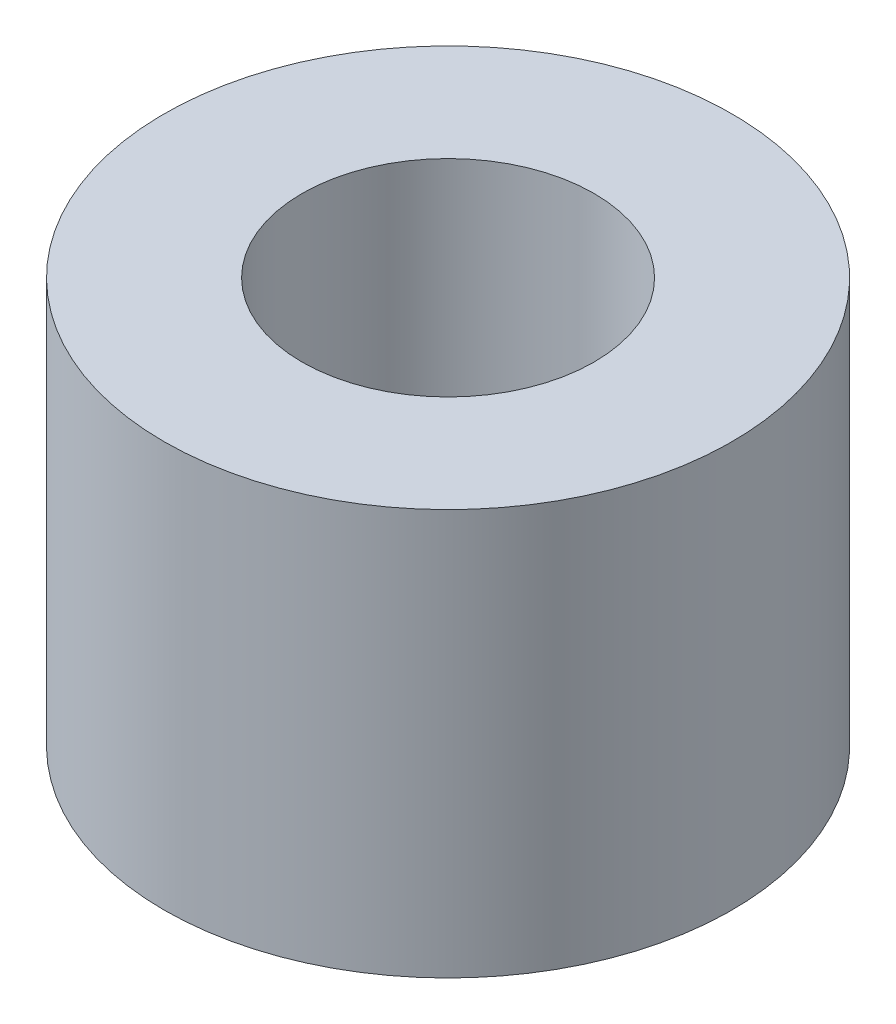
from build123d import *

# Parameters (mm, degrees)
SKETCH1_R           = 3.5
SKETCH1_R_2         = 1.8
BOSS_EXTRUDE1_DEPTH = 2.5


with BuildPart() as part:
    # Sketch1 → Boss-Extrude1 (new body, symmetric)
    with BuildSketch(Plane(origin=(0, 0, 0), x_dir=(1, 0, 0), z_dir=(0, 1, 0))):
        Circle(SKETCH1_R)
        Circle(SKETCH1_R_2, mode=Mode.SUBTRACT)
    extrude(amount=BOSS_EXTRUDE1_DEPTH, both=True)


solid = part.part
